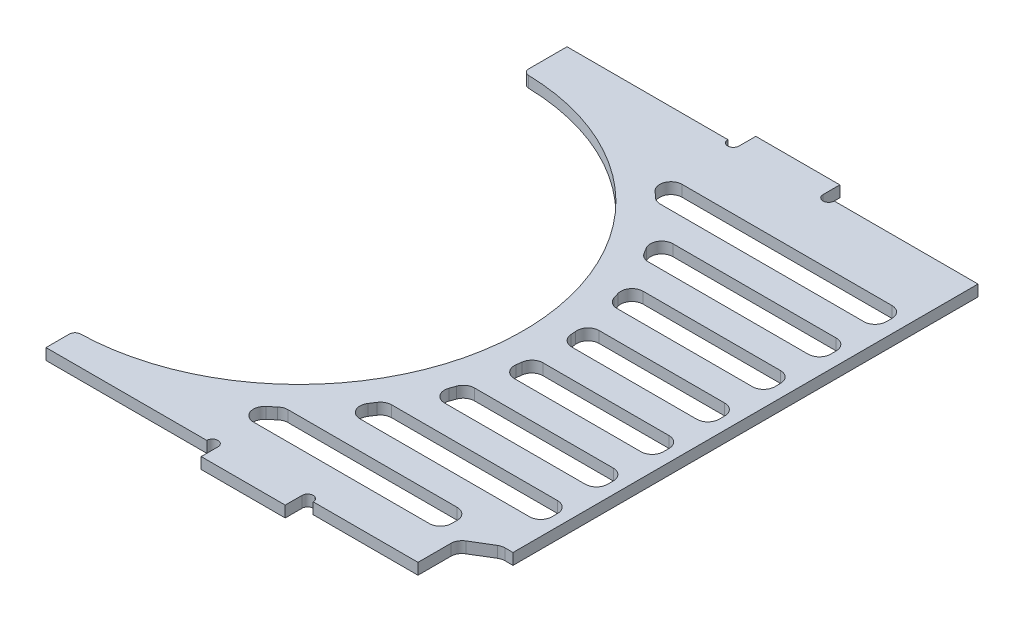
from build123d import *

# Parameters (mm, degrees)
EXTRUDE_1_DEPTH          = 2
SKETCH_3_W               = 76.4
SKETCH_3_H               = 2
EXTRUDE_2_DEPTH          = 7
CUT_EXTRUDE_1_DEPTH      = 10
EXTRUDE_4_DEPTH          = 2
PATTERN_LINEAR_2_COUNT   = 2
PATTERN_LINEAR_2_PITCH   = 32
FILLET_3_R               = 0.5
CUT_EXTRUDE_2_DEPTH      = 10
EXTRUDE_5_DEPTH          = 2
CUT_EXTRUDE_3_DEPTH      = 10
CUT_EXTRUDE_4_DEPTH      = 10
FILLET_5_R               = 2
EXTRUDE_9_DEPTH          = 2
FILLET_6_R               = 2
FILLET_7_R               = 1
SKETCH_18_W              = 76.4
SKETCH_18_H              = 2
EXTRUDE_6_DEPTH          = 2
SKETCH_19_W              = 10
SKETCH_19_H              = 10
CUT_EXTRUDE_5_DEPTH      = 3
EXTRUDE_8_DEPTH          = 2
FILLET_8_R               = 2
FILLET_9_R               = 2
SKETCH_21_W              = 3
SKETCH_21_H              = 87.342834434
CUT_EXTRUDE_6_DEPTH      = 3
CUT_EXTRUDE_7_DEPTH      = 1
CUT_EXTRUDE_7_DEPTH_BACK = 3
SKETCH_24_W              = 15
SKETCH_24_H              = 2
EXTRUDE_10_DEPTH         = 3
SKETCH_25_R              = 1
CUT_EXTRUDE_8_DEPTH      = 3


with BuildPart() as part:
    # 草图1 → 凸台-拉伸1 (new body)
    with BuildSketch(Plane(origin=(0, 0, 0), x_dir=(1, 0, 0), z_dir=(0, 1, 0))):
        with BuildLine():
            Line((-38.2, -42.69), (-38.2, -45.85))
            Line((-38.2, -45.85), (38.2, -45.85))
            Line((38.2, -45.85), (38.2, 45.85))
            Line((38.2, 45.85), (-38.2, 45.85))
            Line((-38.2, 45.85), (-38.2, 37.31))
            ThreePointArc((-38.2, 37.31), (1.8, -2.69), (-38.2, -42.69))
        make_face()
    extrude(amount=EXTRUDE_1_DEPTH)

    # 草图3 → 凸台-拉伸2 (add)
    with BuildSketch(Plane(origin=(0, 0, -45.85), x_dir=(-1, 0, 0), z_dir=(0, 0, -1))):
        with Locations((0, 1)):
            Rectangle(SKETCH_3_W, SKETCH_3_H)
    extrude(amount=EXTRUDE_2_DEPTH)

    # 草图5 → 切除-拉伸1 (cut)
    with BuildSketch(Plane(origin=(0, 2, 0), x_dir=(1, 0, 0), z_dir=(0, 1, 0))):
        Polygon((-38.2, 51.26), (38.2, 52.85), (-38.2, 52.85), align=None)
    extrude(amount=-CUT_EXTRUDE_1_DEPTH, mode=Mode.SUBTRACT)

    # 草图7 → 凸台-拉伸4 (add)
    with BuildSketch(Plane.XZ):
        Polygon((25.6, -52.587774869), (25.6, -54.754790576), (9.6, -54.754790576), (9.6, -52.254790576), align=None)
    extrude_4 = extrude(amount=-EXTRUDE_4_DEPTH)

    # 阵列(线性)2: 凸台-拉伸4 ×2
    with Locations(*[Vector(-0.999783511, 0, 0.020807013) * (i * PATTERN_LINEAR_2_PITCH) for i in range(1, PATTERN_LINEAR_2_COUNT)]):
        add(extrude_4)

    # 圆角3
    fillet_3_edges = [part.edges().sort_by_distance(p)[0] for p in [
        (25.6, 1, -54.754790576),
        (9.6, 1, -54.754790576),
        (-6.393072342, 1, -54.088966165),
        (-22.393072342, 1, -54.088966165),
    ]]
    fillet(fillet_3_edges, radius=FILLET_3_R)

    # 草图10 → 切除-拉伸2 (cut)
    with BuildSketch(Plane(origin=(0, 2, 0), x_dir=(1, 0, 0), z_dir=(0, 1, 0))):
        Polygon((-38.882265213, 53.905585721), (39.585789662, 55.538625083), (39.585789662, 48.538625083), (-38.2, 46.919784696), (-39.22769149, 52.889737929), align=None)
    extrude(amount=-CUT_EXTRUDE_2_DEPTH, mode=Mode.SUBTRACT)

    # 草图11 → 凸台-拉伸5 (add)
    with BuildSketch(Plane(origin=(0, 2, 0), x_dir=(1, 0, 0), z_dir=(0, 1, 0))):
        Polygon((-38.2, 46.919784696), (38.2, 49.509784696), (38.2, 48.509784696), align=None)
    extrude(amount=-EXTRUDE_5_DEPTH)

    # 草图13 → 切除-拉伸3 (cut)
    with BuildSketch(Plane.XZ):
        Polygon((38.2, -49.509784696), (37.7, -49.492834434), (38.2, 45.85), align=None)
    extrude(amount=-CUT_EXTRUDE_3_DEPTH, mode=Mode.SUBTRACT)

    # 草图16 → 切除-拉伸4 (cut)
    with BuildSketch(Plane.XZ):
        with BuildLine():
            ThreePointArc((-21.63159016, -39.14883119), (-26.948214114, -40.880601492), (-32.438562967, -41.939652064))
            Line((-32.438562967, -41.939652064), (32.727956442, -44.14883119))
            Line((32.727956442, -44.14883119), (32.754177605, -39.14883119))
            Line((32.754177605, -39.14883119), (-21.63159016, -39.14883119))
        make_face()
        with BuildLine():
            ThreePointArc((-6.399232266, -29.14883119), (-9.26951053, -31.777764346), (-12.35622867, -34.14883119))
            Line((-12.35622867, -34.14883119), (32.780398767, -34.14883119))
            Line((32.780398767, -34.14883119), (32.80661993, -29.14883119))
            Line((32.80661993, -29.14883119), (-6.399232266, -29.14883119))
        make_face()
        with BuildLine():
            ThreePointArc((1.145462918, -19.14883119), (-0.38438284, -21.702193399), (-2.079685213, -24.14883119))
            Line((-2.079685213, -24.14883119), (32.832841093, -24.14883119))
            Line((32.832841093, -24.14883119), (32.859062256, -19.14883119))
            Line((32.859062256, -19.14883119), (1.145462918, -19.14883119))
        make_face()
        with BuildLine():
            ThreePointArc((5.214767949, -9.14883119), (4.446089194, -11.673532869), (3.530729255, -14.14883119))
            Line((3.530729255, -14.14883119), (32.885283419, -14.14883119))
            Line((32.885283419, -14.14883119), (32.911504582, -9.14883119))
            Line((32.911504582, -9.14883119), (5.214767949, -9.14883119))
        make_face()
        with BuildLine():
            Line((32.937725745, -4.14883119), (32.963946908, 0.85116881))
            Line((32.963946908, 0.85116881), (6.762414302, 0.85116881))
            ThreePointArc((6.762414302, 0.85116881), (6.58968308, -1.65560578), (6.277301941, -4.14883119))
            Line((6.277301941, -4.14883119), (32.937725745, -4.14883119))
        make_face()
        with BuildLine():
            Line((33.016389234, 10.85116881), (6.053760559, 10.85116881))
            ThreePointArc((6.053760559, 10.85116881), (6.441352349, 8.360067057), (6.688829476, 5.85116881))
            Line((6.688829476, 5.85116881), (32.990168071, 5.85116881))
            Line((32.990168071, 5.85116881), (33.016389234, 10.85116881))
        make_face()
        with BuildLine():
            Line((33.06883156, 20.85116881), (2.97246589, 20.85116881))
            ThreePointArc((2.97246589, 20.85116881), (3.976569254, 18.378754125), (4.832355682, 15.85116881))
            Line((4.832355682, 15.85116881), (33.042610397, 15.85116881))
            Line((33.042610397, 15.85116881), (33.06883156, 20.85116881))
        make_face()
        with BuildLine():
            Line((33.121273886, 30.85116881), (-3.100875064, 30.85116881))
            ThreePointArc((-3.100875064, 30.85116881), (-1.274777634, 28.410185715), (0.381864384, 25.85116881))
            Line((0.381864384, 25.85116881), (33.095052723, 25.85116881))
            Line((33.095052723, 25.85116881), (33.121273886, 30.85116881))
        make_face()
        with BuildLine():
            Line((33.173710083, 40.85), (-14.350169812, 40.85))
            ThreePointArc((-14.350169812, 40.85), (-10.950539992, 38.501547429), (-7.780649528, 35.85116881))
            Line((-7.780649528, 35.85116881), (33.147495049, 35.85116881))
            Line((33.147495049, 35.85116881), (33.173710083, 40.85))
        make_face()
    extrude(amount=-CUT_EXTRUDE_4_DEPTH, mode=Mode.SUBTRACT)

    # 圆角5
    fillet_5_edges = [part.edges().sort_by_distance(p)[0] for p in [
        (-21.63159016, 1, -39.14883119),
        (32.754177605, 1, -39.14883119),
        (32.727956442, 1, -44.14883119),
        (-6.399232266, 1, -29.14883119),
        (32.80661993, 1, -29.14883119),
        (32.780398767, 1, -34.14883119),
        (-2.079685213, 1, -24.14883119),
        (3.530729255, 1, -14.14883119),
        (5.214767949, 1, -9.14883119),
        (32.911504582, 1, -9.14883119),
        (32.885283419, 1, -14.14883119),
        (32.937725745, 1, -4.14883119),
        (6.688829476, 1, 5.85116881),
        (33.016389234, 1, 10.85116881),
        (32.990168071, 1, 5.85116881),
        (4.832355682, 1, 15.85116881),
        (2.97246589, 1, 20.85116881),
        (0.381864384, 1, 25.85116881),
        (-3.100875064, 1, 30.85116881),
        (33.121273886, 1, 30.85116881),
        (-14.350169812, 1, 40.85),
        (33.173710083, 1, 40.85),
    ]]
    fillet(fillet_5_edges, radius=FILLET_5_R)

    # 草图23 → 凸台-拉伸9 (add)
    with BuildSketch(Plane.XZ):
        with BuildLine():
            Line((30.743661638, -39.14883119), (-21.254296123, -39.14883119))
            ThreePointArc((-21.254296123, -39.14883119), (-21.621062836, -39.182748237), (-21.975389905, -39.283349012))
            ThreePointArc((-21.975389905, -39.283349012), (-27.127035015, -40.926389654), (-32.438562967, -41.939652064))
            Line((-32.438562967, -41.939652064), (30.67101495, -44.079099797))
            ThreePointArc((30.67101495, -44.079099797), (32.125051399, -43.521859473), (32.738749569, -42.090736373))
            Line((32.738749569, -42.090736373), (32.743634136, -41.159319511))
            ThreePointArc((32.743634136, -41.159319511), (32.161578532, -39.738330684), (30.743661638, -39.14883119))
        make_face()
    extrude(amount=-EXTRUDE_9_DEPTH)

    # 圆角6
    fillet_6_edges = [part.edges().sort_by_distance(p)[0] for p in [
        (-12.35622867, 1, -34.14883119),
        (1.145462918, 1, -19.14883119),
        (32.859062256, 1, -19.14883119),
        (32.832841093, 1, -24.14883119),
        (6.277301941, 1, -4.14883119),
        (6.762414302, 1, 0.85116881),
        (32.963946908, 1, 0.85116881),
        (6.053760559, 1, 10.85116881),
        (33.06883156, 1, 20.85116881),
        (33.042610397, 1, 15.85116881),
        (33.095052723, 1, 25.85116881),
        (-7.780649528, 1, 35.85116881),
        (33.147495049, 1, 35.85116881),
    ]]
    fillet(fillet_6_edges, radius=FILLET_6_R)

    # 圆角7
    fillet_7_edges = [part.edges().sort_by_distance(p)[0] for p in [
        (-38.2, 1, 42.69),
        (-38.2, 1, -37.31),
        (-38.2, 1, -46.919784696),
    ]]
    fillet(fillet_7_edges, radius=FILLET_7_R)

    # 草图18 → 凸台-拉伸6 (add)
    with BuildSketch(Plane.XY.offset(45.85)):
        with Locations((0, 1)):
            Rectangle(SKETCH_18_W, SKETCH_18_H)
    extrude(amount=EXTRUDE_6_DEPTH)

    # 草图19 → 切除-拉伸5 (cut, through all)
    with BuildSketch(Plane(origin=(0, 2, 0), x_dir=(1, 0, 0), z_dir=(0, 1, 0))):
        with Locations((33.2, -42.85)):
            Rectangle(SKETCH_19_W, SKETCH_19_H)
    extrude(amount=-CUT_EXTRUDE_5_DEPTH, mode=Mode.SUBTRACT)

    # 草图20 → 凸台-拉伸8 (add)
    with BuildSketch(Plane(origin=(0, 2, 0), x_dir=(1, 0, 0), z_dir=(0, 1, 0))):
        Polygon((25.2, -35.85116881), (33.157977385, -35.85116881), (33.157977385, -37.85), (28.2, -40.85), (25.2, -40.85), align=None)
    extrude(amount=-EXTRUDE_8_DEPTH)

    # 圆角8
    fillet_8_edges = [part.edges().sort_by_distance(p)[0] for p in [
        (25.2, 1, 40.85),
        (25.2, 1, 35.85116881),
    ]]
    fillet(fillet_8_edges, radius=FILLET_8_R)

    # 圆角9
    fillet_9_edges = [part.edges().sort_by_distance(p)[0] for p in [
        (33.157977385, 1, 37.85),
        (28.2, 1, 40.85),
    ]]
    fillet(fillet_9_edges, radius=FILLET_9_R)

    # 草图21 → 切除-拉伸6 (cut, through all)
    with BuildSketch(Plane.XZ):
        with Locations((36.658046139, -5.821417217)):
            Rectangle(SKETCH_21_W, SKETCH_21_H)
    extrude(amount=-CUT_EXTRUDE_6_DEPTH, mode=Mode.SUBTRACT)

    # 草图22 → 切除-拉伸7 (cut, two sides)
    with BuildSketch(Plane.XZ) as cut_extrude_7_sk:
        Polygon((-290.579437235, -45.15), (-39.244125604, -45.15), (60.755874396, -45.15), (60.755874396, -51.15), (-39.244125604, -51.15), (-39.244125604, -47.15), (-39.244125604, 204.185311631), (314.77499341, -152.673510404), (63.439681778, -402.008822036), align=None)
    extrude(amount=CUT_EXTRUDE_7_DEPTH, mode=Mode.SUBTRACT)
    extrude(cut_extrude_7_sk.sketch, amount=-CUT_EXTRUDE_7_DEPTH_BACK, mode=Mode.SUBTRACT)

    # 草图24 → 凸台-拉伸10 (add)
    with BuildSketch(Plane(origin=(0, 0, -45.15), x_dir=(-1, 0, 0), z_dir=(0, 0, -1))):
        with Locations((0, 1)):
            Rectangle(SKETCH_24_W, SKETCH_24_H)
    extrude_10 = extrude(amount=EXTRUDE_10_DEPTH)

    # 草图25 → 切除-拉伸8 (cut, through all)
    with BuildSketch(Plane(origin=(0, 2, 0), x_dir=(1, 0, 0), z_dir=(0, 1, 0))):
        with Locations((-8.5, 45.15)):
            Circle(SKETCH_25_R)
        with Locations((8.5, 45.15)):
            Circle(SKETCH_25_R)
    cut_extrude_8 = extrude(amount=-CUT_EXTRUDE_8_DEPTH, mode=Mode.SUBTRACT)

    # 镜向1: 凸台-拉伸10, 切除-拉伸8 across plane
    add(extrude_10.mirror(Plane.XY.offset(1.35)))
    add(cut_extrude_8.mirror(Plane.XY.offset(1.35)), mode=Mode.SUBTRACT)


solid = part.part
